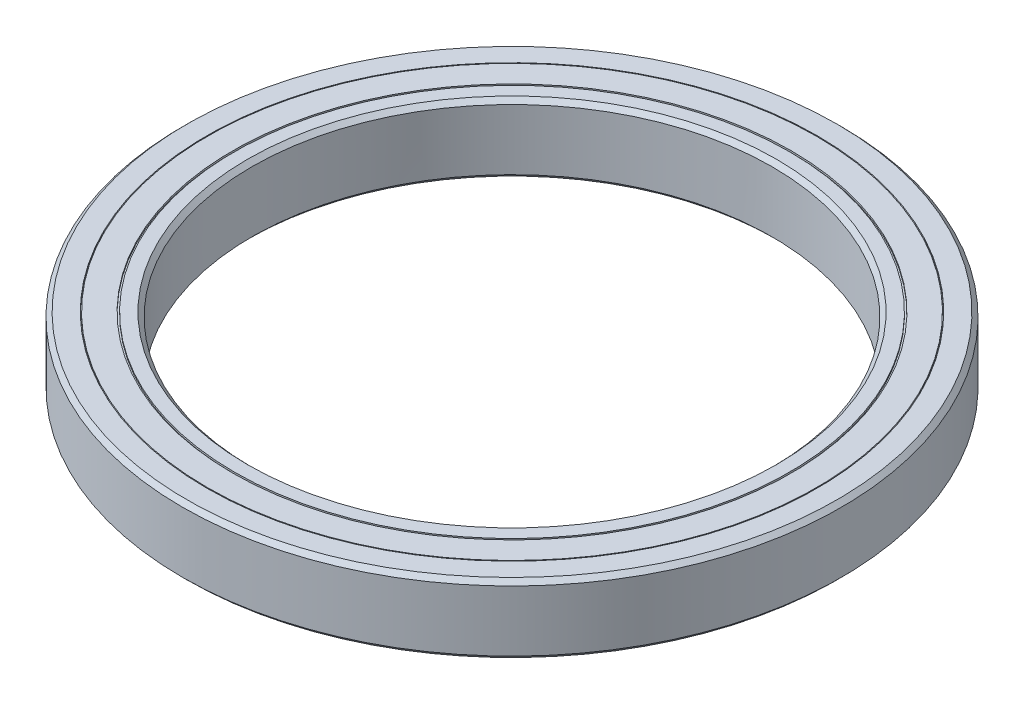
from build123d import *

# Parameters (mm, degrees)
CHAMFER_1_SIZE = 0.5


with BuildPart() as part:
    # 草图1 → 旋转1 (revolve)
    with BuildSketch(Plane.XY):
        Polygon((30, -4), (30, 4), (32, 4), (32, 3.8), (32.2, 3.8), (32.2, 4), (35.1, 4), (35.1, 3.8), (35.2, 3.8), (35.2, 4), (38, 4), (38, -4), (35.2, -4), (35.2, -3.8), (35.1, -3.8), (35.1, -4), (32.2, -4), (32.2, -3.8), (32, -3.8), (32, -4), align=None)
    revolve(axis=Axis((0, 60.459632728, 0), (0, -1, 0)))

    # 倒角1
    chamfer_1_edges = [part.edges().sort_by_distance(p)[0] for p in [
        (-38, 4, 0),
        (-38, -4, 0),
        (-30, -4, 0),
        (-30, 4, 0),
    ]]
    chamfer(chamfer_1_edges, length=CHAMFER_1_SIZE)


solid = part.part
